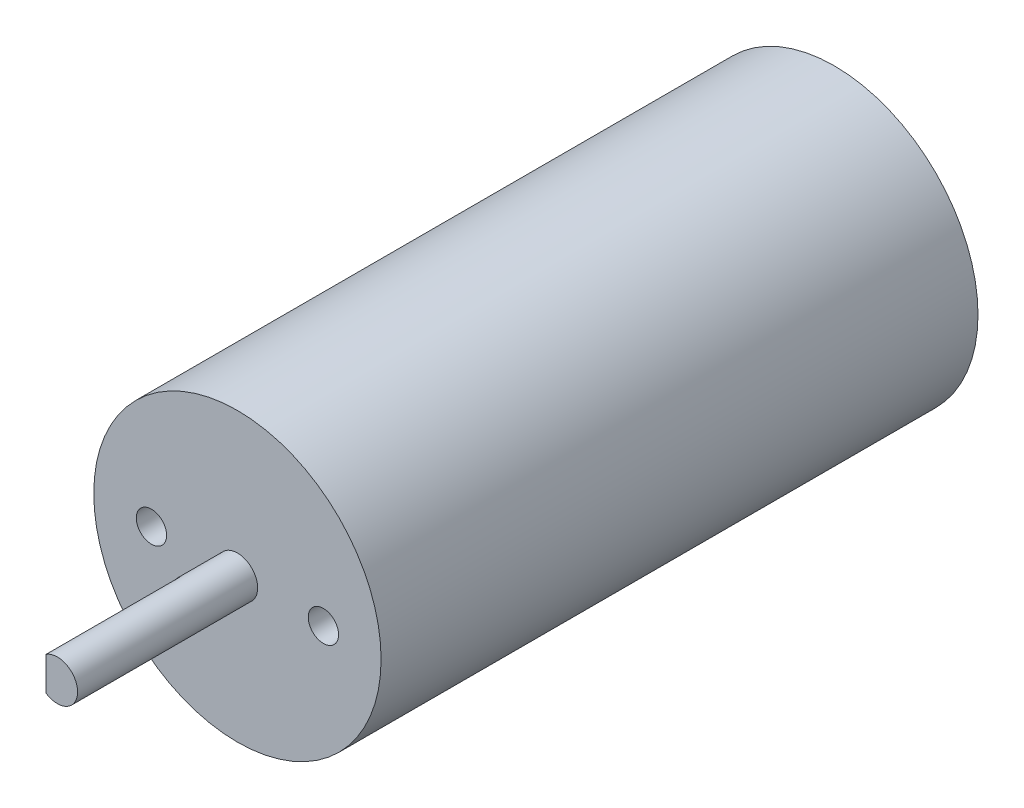
from build123d import *

# Parameters (mm, degrees)
SKETCH1_R           = 14.2
BOSS_EXTRUDE1_DEPTH = 59
SKETCH2_R           = 2
BOSS_EXTRUDE2_DEPTH = 17.8
SKETCH3_R           = 1.5
CUT_EXTRUDE1_DEPTH  = 4.3942
SKETCH5_W           = 1.529717974
SKETCH5_H           = 4.18122913
CUT_EXTRUDE2_DEPTH  = 13.716


with BuildPart() as part:
    # Sketch1 → Boss-Extrude1 (new body)
    with BuildSketch(Plane.XY):
        Circle(SKETCH1_R)
    extrude(amount=BOSS_EXTRUDE1_DEPTH)

    # Sketch2 → Boss-Extrude2 (add)
    with BuildSketch(Plane.XY.offset(59)):
        Circle(SKETCH2_R)
    extrude(amount=BOSS_EXTRUDE2_DEPTH)

    # Sketch3 → Cut-Extrude1 (cut)
    with BuildSketch(Plane.XY.offset(59)):
        with Locations((-8.5, 0)):
            Circle(SKETCH3_R)
        with Locations((8.5, 0)):
            Circle(SKETCH3_R)
    extrude(amount=-CUT_EXTRUDE1_DEPTH, mode=Mode.SUBTRACT)

    # Sketch5 → Cut-Extrude2 (cut)
    with BuildSketch(Plane.XY.offset(63.5)):
        with Locations((-1.886652168, -0.050990599)):
            Rectangle(SKETCH5_W, SKETCH5_H)
    extrude(amount=CUT_EXTRUDE2_DEPTH, mode=Mode.SUBTRACT)


solid = part.part
